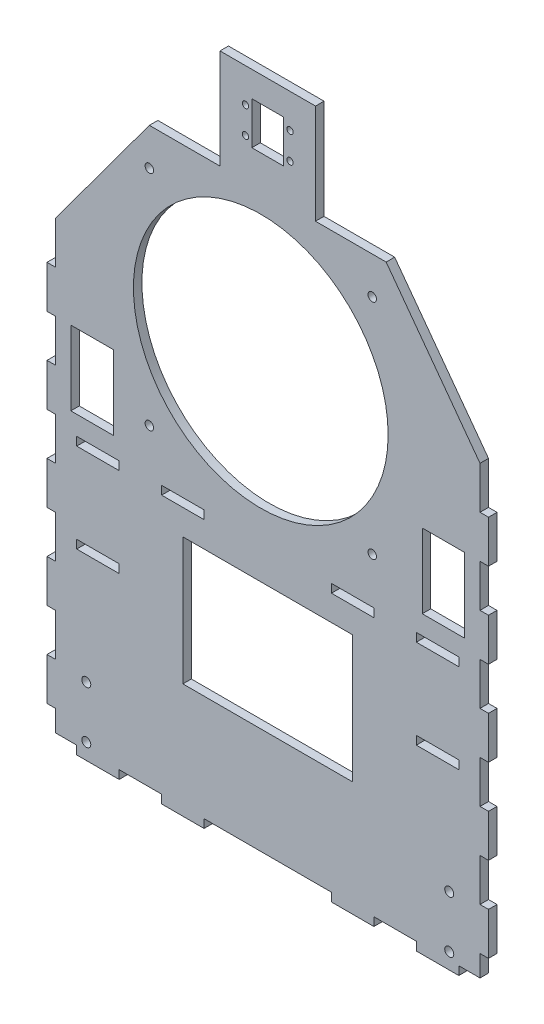
from build123d import *

# Parameters (mm, degrees)
SKICA1_R                = 2.125
SKICA1_W                = 20
SKICA1_H                = 4
SKICA1_H_2              = 35
SKICA1_R_2              = 2
SKICA1_W_2              = 80
SKICA1_H_3              = 60
SKICA1_R_3              = 60
SKICA1_R_4              = 1.5
SKICA1_W_3              = 15
SKICA1_H_4              = 20
P_IDAT_VYSUNUT_M1_DEPTH = 4


with BuildPart() as part:
    # Skica1 → Přidat vysunutím1 (new body)
    with BuildSketch(Plane.XY):
        Polygon((0, 0), (0, 10), (4, 10), (4, 30), (0, 30), (0, 50), (4, 50), (4, 70), (0, 70), (0, 90), (4, 90), (4, 110), (0, 110), (0, 130), (4, 130), (4, 150), (0, 150), (0, 170), (4, 170), (4, 190), (0, 190), (0, 210), (-44.218272824, 270), (-77.5, 270), (-77.5, 317), (-122.5, 317), (-122.5, 270), (-155.781727176, 270), (-200, 210), (-200, 190), (-204, 190), (-204, 170), (-200, 170), (-200, 150), (-204, 150), (-204, 130), (-200, 130), (-200, 110), (-204, 110), (-204, 90), (-200, 90), (-200, 70), (-204, 70), (-204, 50), (-200, 50), (-200, 30), (-204, 30), (-204, 10), (-200, 10), (-200, 0), (-190, 0), (-190, -4), (-170, -4), (-170, 0), (-150, 0), (-150, -4), (-130, -4), (-130, 0), (-70, 0), (-70, -4), (-50, -4), (-50, 0), (-30, 0), (-30, -4), (-10, -4), (-10, 0), align=None)
        with Locations((-185.5, 3.5)):
            Circle(SKICA1_R, mode=Mode.SUBTRACT)
        with Locations((-185.5, 28)):
            Circle(SKICA1_R, mode=Mode.SUBTRACT)
        with Locations((-180, 82)):
            Rectangle(SKICA1_W, SKICA1_H, mode=Mode.SUBTRACT)
        with Locations((-180, 124)):
            Rectangle(SKICA1_W, SKICA1_H, mode=Mode.SUBTRACT)
        with Locations((-182.785843761, 152.5)):
            Rectangle(SKICA1_W, SKICA1_H_2, mode=Mode.SUBTRACT)
        with Locations((-155.781727176, 147.5)):
            Circle(SKICA1_R_2, mode=Mode.SUBTRACT)
        with Locations((-140, 124)):
            Rectangle(SKICA1_W, SKICA1_H, mode=Mode.SUBTRACT)
        with Locations((-14.5, 3.5)):
            Circle(SKICA1_R, mode=Mode.SUBTRACT)
        with Locations((-14.5, 28)):
            Circle(SKICA1_R, mode=Mode.SUBTRACT)
        with Locations((-100, 80)):
            Rectangle(SKICA1_W_2, SKICA1_H_3, mode=Mode.SUBTRACT)
        with Locations((-60, 124)):
            Rectangle(SKICA1_W, SKICA1_H, mode=Mode.SUBTRACT)
        with Locations((-50.781727176, 147.5)):
            Circle(SKICA1_R_2, mode=Mode.SUBTRACT)
        with Locations((-20, 82)):
            Rectangle(SKICA1_W, SKICA1_H, mode=Mode.SUBTRACT)
        with Locations((-20, 124)):
            Rectangle(SKICA1_W, SKICA1_H, mode=Mode.SUBTRACT)
        with Locations((-17.214156239, 152.5)):
            Rectangle(SKICA1_W, SKICA1_H_2, mode=Mode.SUBTRACT)
        with Locations((-103.281727176, 200)):
            Circle(SKICA1_R_3, mode=Mode.SUBTRACT)
        with Locations((-155.781727176, 252.5)):
            Circle(SKICA1_R_2, mode=Mode.SUBTRACT)
        with Locations((-50.781727176, 252.5)):
            Circle(SKICA1_R_2, mode=Mode.SUBTRACT)
        with Locations((-89.5, 301)):
            Circle(SKICA1_R_4, mode=Mode.SUBTRACT)
        with Locations((-110.5, 288.5)):
            Circle(SKICA1_R_4, mode=Mode.SUBTRACT)
        with Locations((-100, 295)):
            Rectangle(SKICA1_W_3, SKICA1_H_4, mode=Mode.SUBTRACT)
        with Locations((-110.5, 301)):
            Circle(SKICA1_R_4, mode=Mode.SUBTRACT)
        with Locations((-89.5, 288.5)):
            Circle(SKICA1_R_4, mode=Mode.SUBTRACT)
    extrude(amount=P_IDAT_VYSUNUT_M1_DEPTH)


solid = part.part
